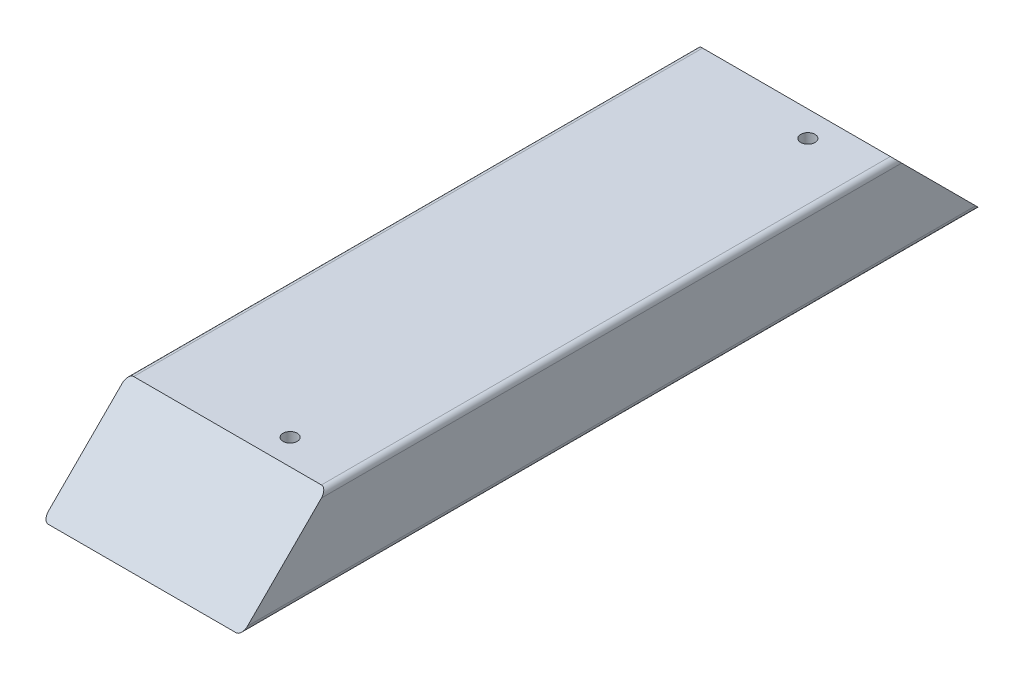
from build123d import *

# Parameters (mm, degrees)
SKETCH1_W           = 88.9
SKETCH1_H           = 38.1
BOSS_EXTRUDE1_DEPTH = 330.2
FILLET1_R           = 2.54
CUT_EXTRUDE1_DEPTH  = 406.4
SKETCH3_R           = 3.175
CUT_EXTRUDE2_DEPTH  = 12.7


with BuildPart() as part:
    # Sketch1 → Boss-Extrude1 (new body)
    with BuildSketch(Plane.XY):
        Rectangle(SKETCH1_W, SKETCH1_H)
    extrude(amount=BOSS_EXTRUDE1_DEPTH)

    # Fillet1
    fillet1_edges = [part.edges().sort_by_distance(p)[0] for p in [
        (44.45, -19.05, 165.1),
        (-44.45, -19.05, 165.1),
        (-44.45, 19.05, 165.1),
        (44.45, 19.05, 165.1),
    ]]
    fillet(fillet1_edges, radius=FILLET1_R)

    # Sketch2 → Cut-Extrude1 (cut)
    with BuildSketch(Plane.ZY.offset(44.45)):
        Polygon((0, 19.05), (0, -19.05), (38.1, 19.05), align=None)
    cut_extrude1 = extrude(amount=-CUT_EXTRUDE1_DEPTH, mode=Mode.SUBTRACT)

    # Mirror1: Cut-Extrude1 across plane
    add(cut_extrude1.mirror(Plane.XY.offset(165.1)), mode=Mode.SUBTRACT)

    # Sketch3 → Cut-Extrude2 (cut)
    with BuildSketch(Plane(origin=(0, 19.05, 0), x_dir=(1, 0, 0), z_dir=(0, 1, 0))):
        with Locations((16.51, -49.53)):
            Circle(SKETCH3_R)
    cut_extrude2 = extrude(amount=-CUT_EXTRUDE2_DEPTH, mode=Mode.SUBTRACT)

    # Mirror2: Cut-Extrude2 across plane
    add(cut_extrude2.mirror(Plane.XY.offset(165.1)), mode=Mode.SUBTRACT)


solid = part.part
